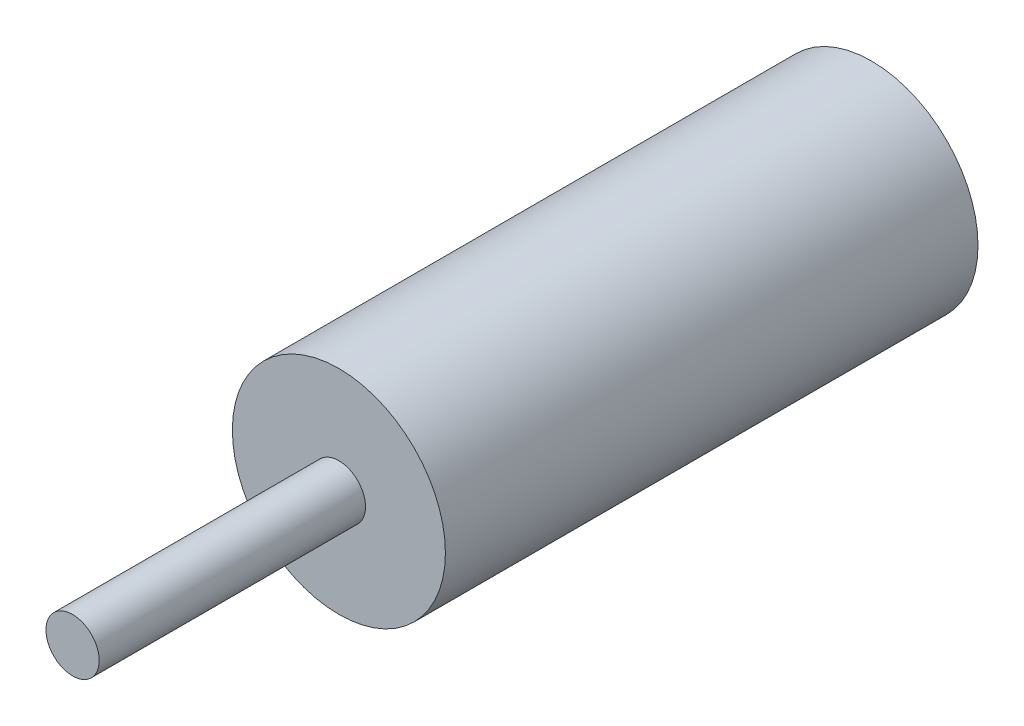
from build123d import *

# Parameters (mm, degrees)
SKETCH1_R           = 4
BOSS_EXTRUDE1_DEPTH = 20
SKETCH1_3_R         = 1
BOSS_EXTRUDE2_DEPTH = 30


with BuildPart() as part:
    # Sketch1 → Boss-Extrude1 (new body)
    with BuildSketch(Plane.XY):
        Circle(SKETCH1_R)
    extrude(amount=BOSS_EXTRUDE1_DEPTH)

    # Sketch1_3 → Boss-Extrude2 (add)
    with BuildSketch(Plane.XY):
        Circle(SKETCH1_3_R)
    extrude(amount=BOSS_EXTRUDE2_DEPTH)


solid = part.part
